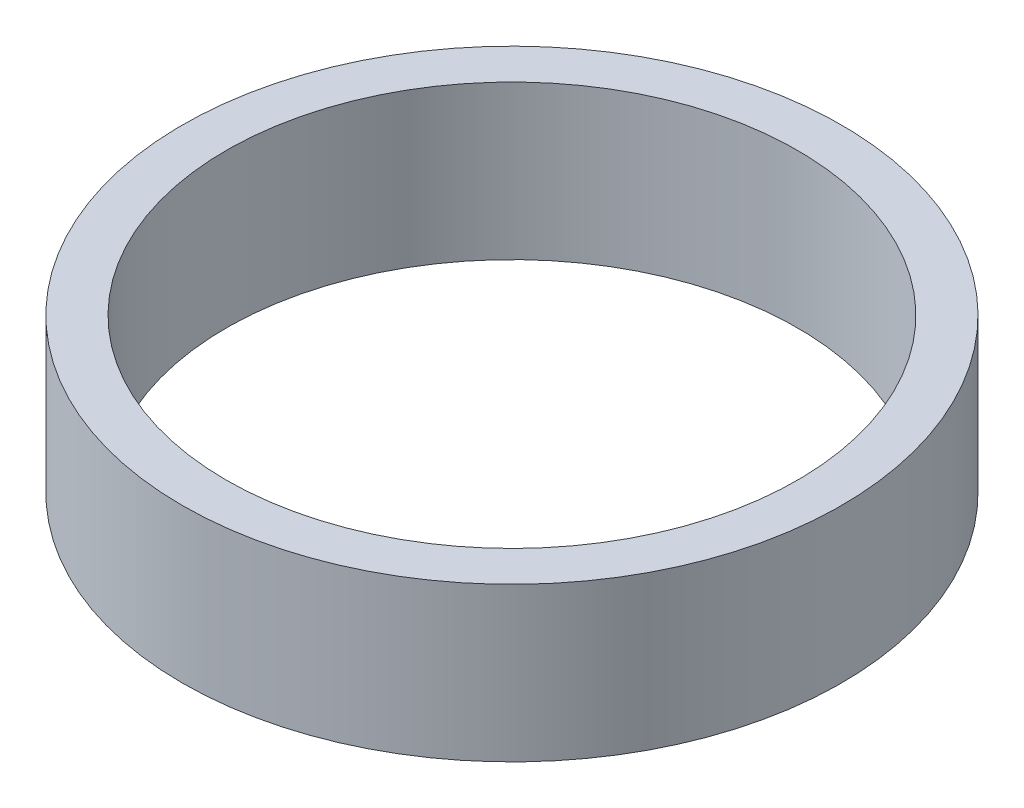
from build123d import *

# Parameters (mm, degrees)
SKETCH2_R           = 7.5
SKETCH2_R_2         = 6.5
BOSS_EXTRUDE1_DEPTH = 3.5


with BuildPart() as part:
    # Sketch2 → Boss-Extrude1 (new body)
    with BuildSketch(Plane(origin=(0, 0, 0), x_dir=(1, 0, 0), z_dir=(0, 1, 0))):
        Circle(SKETCH2_R)
        Circle(SKETCH2_R_2, mode=Mode.SUBTRACT)
    extrude(amount=BOSS_EXTRUDE1_DEPTH)


solid = part.part
